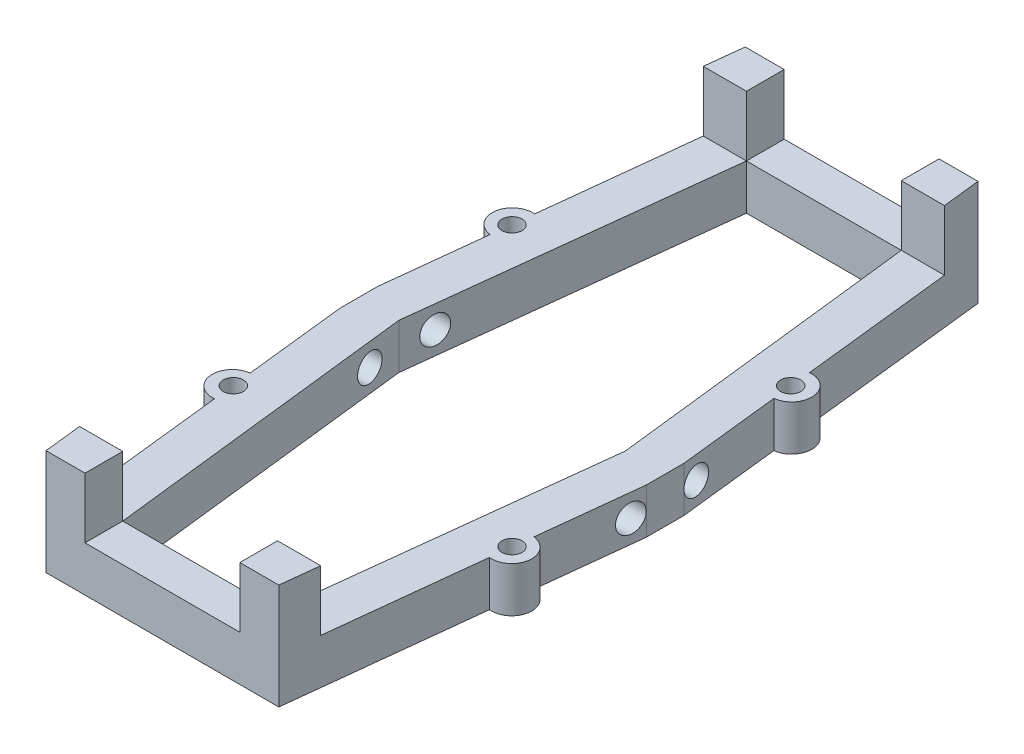
from build123d import *

# Parameters (mm, degrees)
BOSS_EXTRUDE1_DEPTH     = 4.5
BOSS_EXTRUDE5_DEPTH     = 6
SKETCH9_R               = 1
CUT_EXTRUDE2_DEPTH      = 10
SKETCH11_R              = 1.375
CUT_EXTRUDE3_DEPTH      = 1.662978
CUT_EXTRUDE3_DEPTH_BACK = 32.102978


with BuildPart() as part:
    # Sketch1 → Boss-Extrude1 (new body)
    with BuildSketch(Plane(origin=(0, 0, 0), x_dir=(1, 0, 0), z_dir=(0, 1, 0))):
        with BuildLine():
            Line((5.65, -1.875), (5.65, 1.875))
            Line((5.65, 1.875), (1.9, 1.875))
            Line((1.9, 1.875), (-1.875, -31))
            Line((-1.875, -31), (-17.265, -31))
            Line((-17.265, -31), (-21.04, 1.875))
            Line((-21.04, 1.875), (-24.79, 1.875))
            Line((-24.79, 1.875), (-24.79, -1.875))
            Line((-24.79, -1.875), (-23.673675, -11.929569))
            ThreePointArc((-23.673675, -11.929569), (-25.440764, -14.138052), (-23.232281, -15.905141))
            Line((-23.232281, -15.905141), (-21.14, -34.75))
            Line((-21.14, -34.75), (-19.14, -34.75))
            Line((-19.14, -34.75), (0, -34.75))
            Line((0, -34.75), (2, -34.75))
            Line((2, -34.75), (4.092281, -15.905141))
            ThreePointArc((4.092281, -15.905141), (6.300764, -14.138052), (4.533675, -11.929569))
            Line((4.533675, -11.929569), (5.65, -1.875))
        make_face()
    boss_extrude1 = extrude(amount=BOSS_EXTRUDE1_DEPTH)

    # Sketch7 → Boss-Extrude5 (add)
    with BuildSketch(Plane(origin=(0, 4.5, 0), x_dir=(1, 0, 0), z_dir=(0, 1, 0))):
        Polygon((-1.875, -31), (-1.875, -34.75), (2, -34.75), (2.41635, -31), align=None)
        Polygon((-21.55635, -31), (-17.265, -31), (-17.265, -34.75), (-21.14, -34.75), align=None)
    boss_extrude5 = extrude(amount=BOSS_EXTRUDE5_DEPTH)

    # Sketch9 → Cut-Extrude2 (cut)
    with BuildSketch(Plane(origin=(0, 4.5, 0), x_dir=(1, 0, 0), z_dir=(0, 1, 0))):
        with Locations((4.28, 13.85)):
            Circle(SKETCH9_R)
        with Locations((-23.42, 13.85)):
            Circle(SKETCH9_R)
        with Locations((-23.42, -13.85)):
            Circle(SKETCH9_R)
        with Locations((4.28, -13.85)):
            Circle(SKETCH9_R)
    cut_extrude2 = extrude(amount=-CUT_EXTRUDE2_DEPTH, mode=Mode.SUBTRACT)

    # Mirror1: Boss-Extrude1, Boss-Extrude5, Cut-Extrude2 across plane
    add(boss_extrude1.mirror(Plane.XY))
    add(boss_extrude5.mirror(Plane.XY))
    add(cut_extrude2.mirror(Plane.XY), mode=Mode.SUBTRACT)

    # Sketch11 → Cut-Extrude3 (cut, two sides)
    with BuildSketch(Plane(origin=(5.65, 0, 0), x_dir=(0, 0, -1), z_dir=(1, 0, 0))) as cut_extrude3_sk:
        with Locations((-3.25, 2.25)):
            Circle(SKETCH11_R)
        with Locations((3.25, 2.25)):
            Circle(SKETCH11_R)
    extrude(amount=CUT_EXTRUDE3_DEPTH, mode=Mode.SUBTRACT)
    extrude(cut_extrude3_sk.sketch, amount=-CUT_EXTRUDE3_DEPTH_BACK, mode=Mode.SUBTRACT)


solid = part.part
